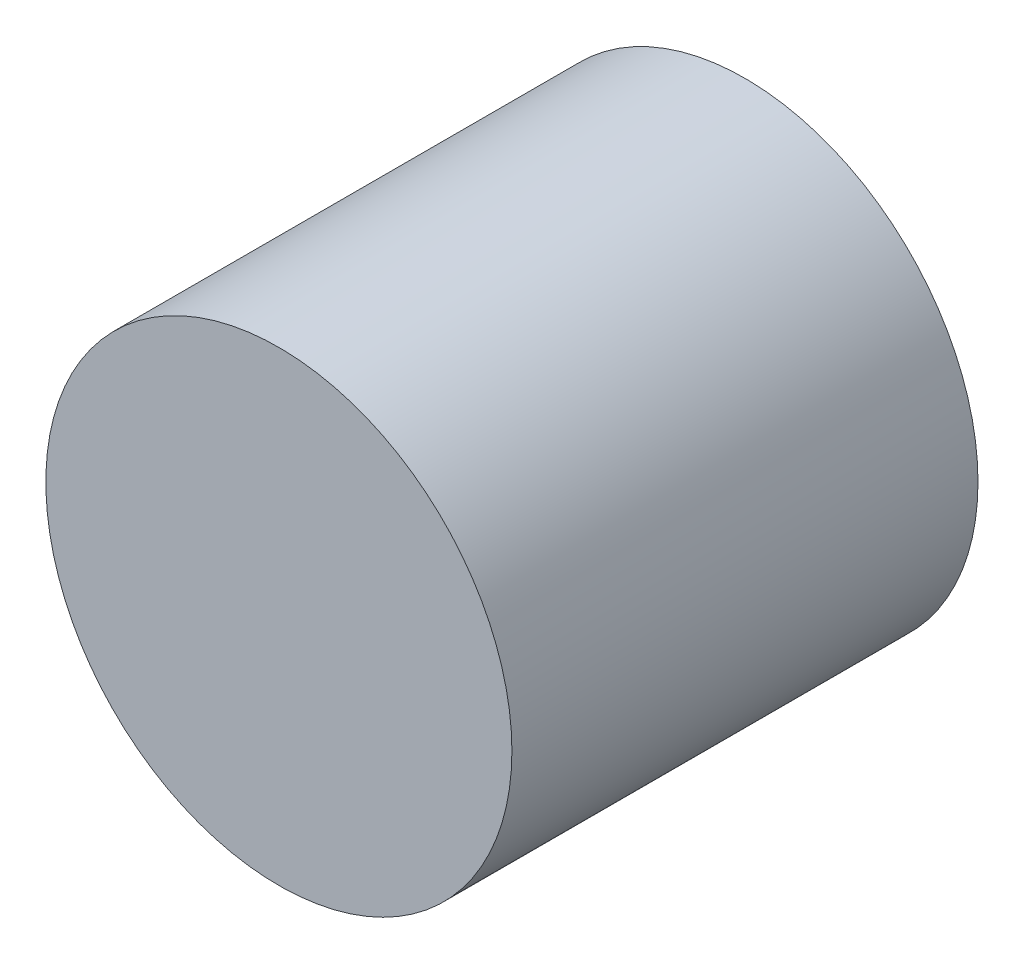
from build123d import *

# Parameters (mm, degrees)
SKETCH1_R           = 3.175
BOSS_EXTRUDE1_DEPTH = 6.35


with BuildPart() as part:
    # Sketch1 → Boss-Extrude1 (new body)
    with BuildSketch(Plane.XY):
        Circle(SKETCH1_R)
    extrude(amount=BOSS_EXTRUDE1_DEPTH)


solid = part.part
